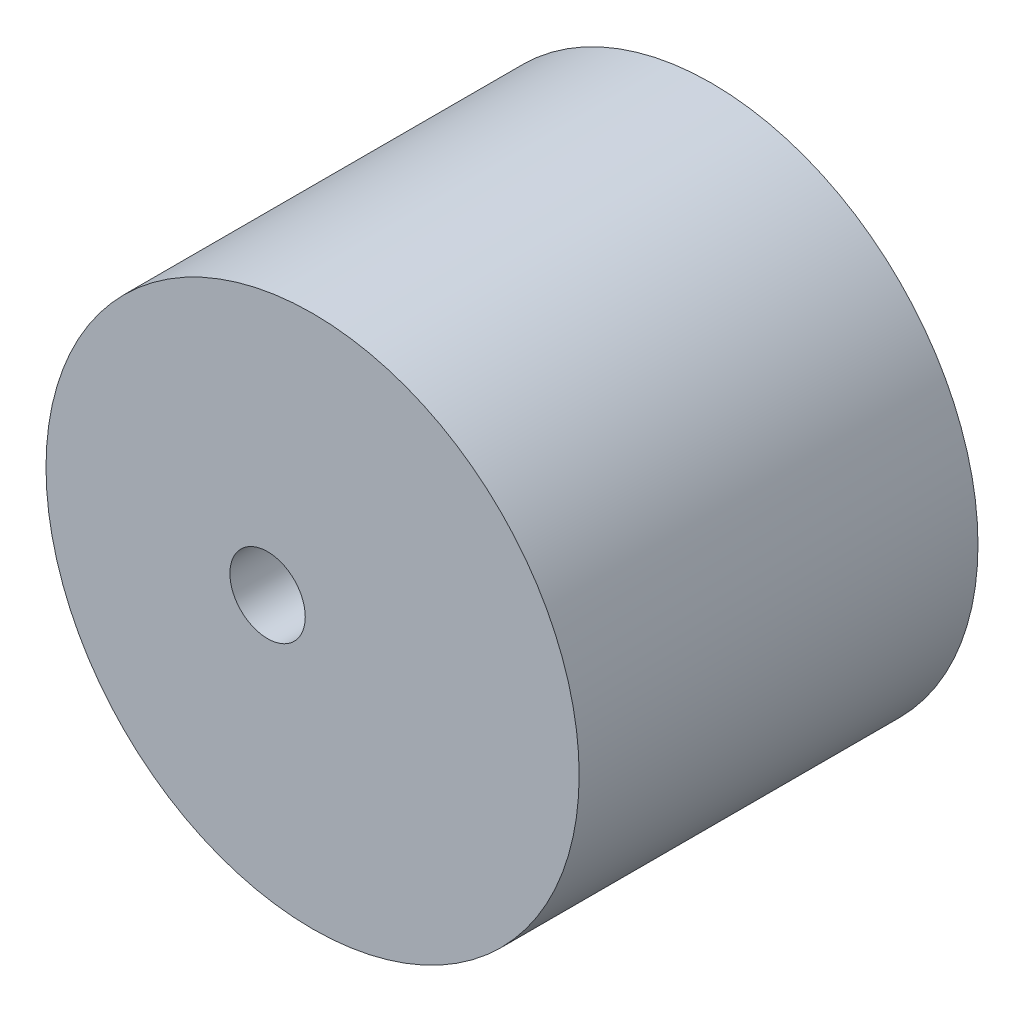
from build123d import *

# Parameters (mm, degrees)
SKETCH11_R           = 23.39375
SKETCH11_R_2         = 3.3085
BOSS_EXTRUDE13_DEPTH = 35


with BuildPart() as part:
    # Sketch11 → Boss-Extrude13 (new body)
    with BuildSketch(Plane.XY):
        Circle(SKETCH11_R)
        with Locations((-3.95, 0)):
            Circle(SKETCH11_R_2, mode=Mode.SUBTRACT)
    extrude(amount=BOSS_EXTRUDE13_DEPTH)


solid = part.part
